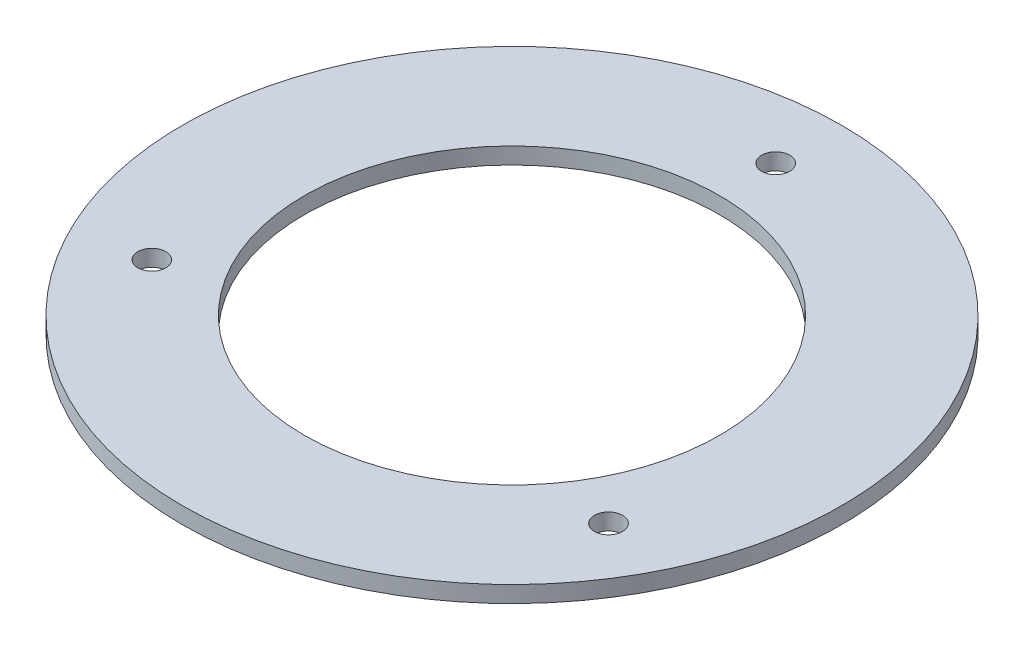
from build123d import *

# Parameters (mm, degrees)
SKETCH1_R           = 63.5
BOSS_EXTRUDE1_DEPTH = 3.18
SKETCH2_R           = 40.005
CUT_EXTRUDE1_DEPTH  = 3.18
CIRPATTERN1_COUNT   = 3


with BuildPart() as part:
    # Sketch1 → Boss-Extrude1 (new body)
    with BuildSketch(Plane(origin=(0, 0, 0), x_dir=(1, 0, 0), z_dir=(0, 1, 0))):
        Circle(SKETCH1_R)
    extrude(amount=BOSS_EXTRUDE1_DEPTH)

    # Sketch2 → Cut-Extrude1 (cut)
    with BuildSketch(Plane(origin=(0, 3.18, 0), x_dir=(1, 0, 0), z_dir=(0, 1, 0))):
        Circle(SKETCH2_R)
    extrude(amount=-CUT_EXTRUDE1_DEPTH, mode=Mode.SUBTRACT)

    # Sketch7 → Hole for #8 300® SC Nuts (SP)1 (revolve, cut)
    with BuildSketch(Plane(origin=(0, 3.18, -50.8), x_dir=(0, 0, 1), z_dir=(1, 0, 0))):
        Polygon((0, 0), (0, 21.375388061), (2.7051, 19.75), (2.7051, 0), align=None)
    hole_for_8_300_sc_nuts_sp_1 = revolve(axis=Axis((0, 9.53, -50.8), (0, -1, 0)), mode=Mode.SUBTRACT)

    # CirPattern1: Hole for #8 300® SC Nuts (SP)1 ×3 about axis
    cirpattern1_axis = Axis((0, 0, 0), (0, 1, 0))
    for i in range(1, CIRPATTERN1_COUNT):
        add(hole_for_8_300_sc_nuts_sp_1.rotate(cirpattern1_axis, i * 360 / CIRPATTERN1_COUNT), mode=Mode.SUBTRACT)


solid = part.part
